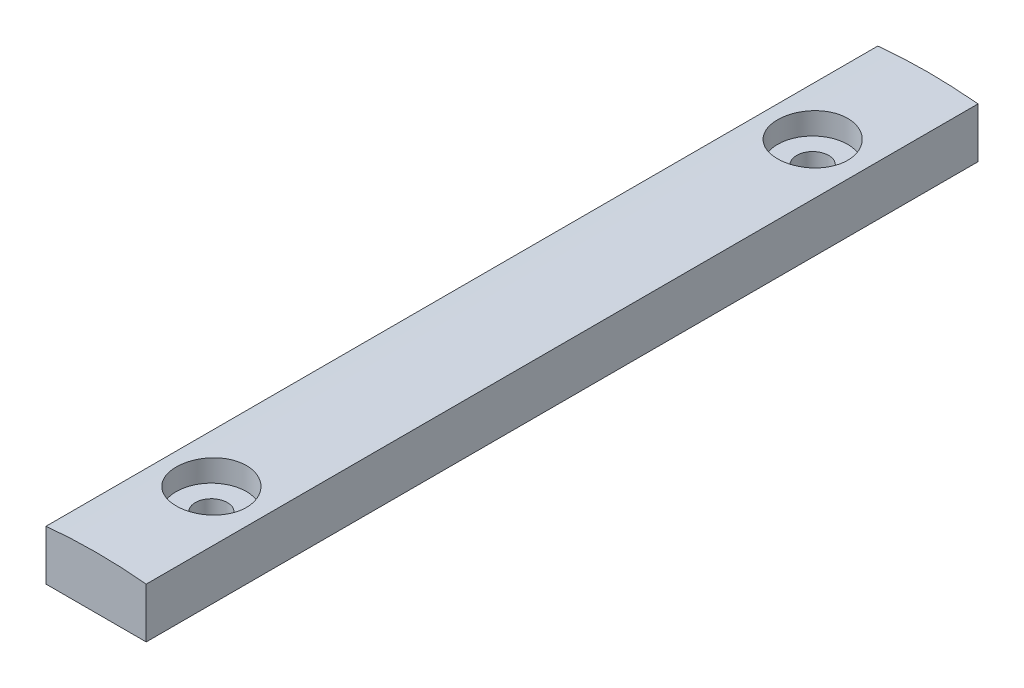
from build123d import *

# Parameters (mm, degrees)
EXTRUDE_1_DEPTH     = 83
CUT_EXTRUDE_START   = -10
SKETCH_6_R          = 1.6
CUT_EXTRUDE_1_DEPTH = 15
SKETCH_5_R          = 3.5
CUT_EXTRUDE_2_DEPTH = 2


with BuildPart() as part:
    # 草图1 → 凸台-拉伸1 (new body)
    with BuildSketch(Plane.XY):
        with BuildLine():
            Line((0, 0), (10, 0))
            Line((10, 0), (10, 5))
            ThreePointArc((10, 5), (5, 5.250628145), (0, 5))
            Line((0, 5), (0, 0))
        make_face()
    extrude(amount=EXTRUDE_1_DEPTH)

    # 草图6 → 切除-拉伸1 (cut)
    with BuildSketch(Plane(origin=(0, 5, 0), x_dir=(1, 0, 0), z_dir=(0, 1, 0)).offset(CUT_EXTRUDE_START)):
        with Locations((5, -71.5)):
            Circle(SKETCH_6_R)
    cut_extrude_1 = extrude(amount=CUT_EXTRUDE_1_DEPTH, mode=Mode.SUBTRACT)

    # 草图5 → 切除-拉伸2 (cut, symmetric)
    with BuildSketch(Plane(origin=(0, 5, 0), x_dir=(1, 0, 0), z_dir=(0, 1, 0))):
        with Locations((5, -71.5)):
            Circle(SKETCH_5_R)
    cut_extrude_2 = extrude(amount=CUT_EXTRUDE_2_DEPTH, both=True, mode=Mode.SUBTRACT)

    # 镜向1: 切除-拉伸1, 切除-拉伸2 across plane
    add(cut_extrude_1.mirror(Plane(origin=(0, 0, 41.5), x_dir=(1, 0, 0), z_dir=(0, 0, -1))), mode=Mode.SUBTRACT)
    add(cut_extrude_2.mirror(Plane(origin=(0, 0, 41.5), x_dir=(1, 0, 0), z_dir=(0, 0, -1))), mode=Mode.SUBTRACT)


solid = part.part
